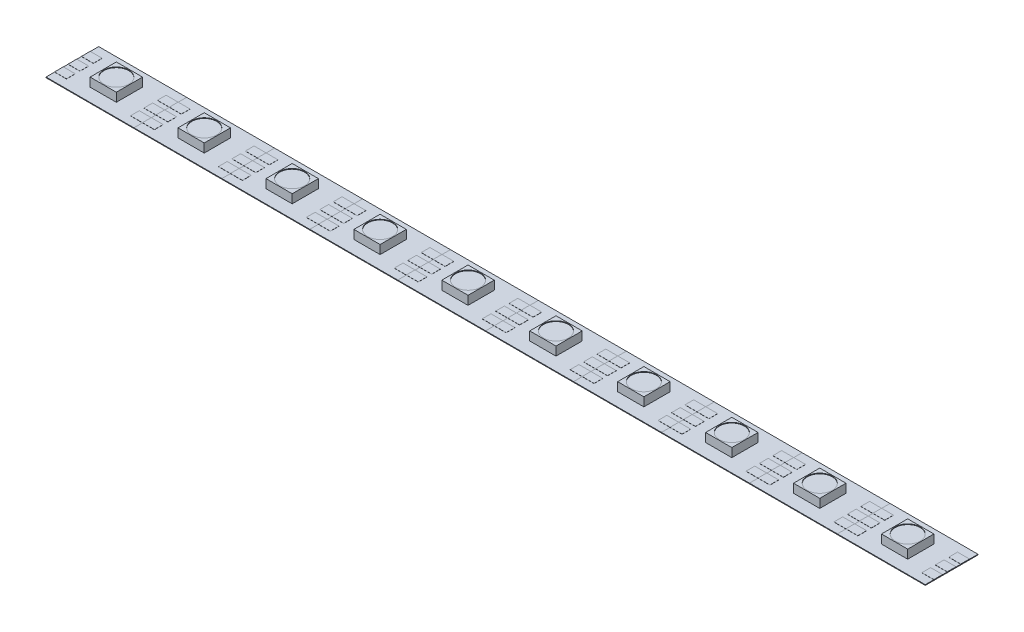
from build123d import *

# Parameters (mm, degrees)
SKETCH1_W           = 16.6116
SKETCH1_H           = 9.9568
BOSS_EXTRUDE1_DEPTH = 0.127
SKETCH3_W           = 4.953
SKETCH3_H           = 4.953
BOSS_EXTRUDE3_DEPTH = 1.651
SKETCH4_W           = 2.258810151
SKETCH4_H           = 1.651
BOSS_EXTRUDE4_DEPTH = 0.0254
SKETCH5_R           = 2.348345572
CUT_EXTRUDE1_DEPTH  = 0.127
LPATTERN1_COUNT     = 10
LPATTERN1_PITCH     = 16.6116


with BuildPart() as part:
    # Sketch1 → Boss-Extrude1 (new body)
    with BuildSketch(Plane(origin=(0, 0, 0), x_dir=(1, 0, 0), z_dir=(0, 1, 0))):
        Rectangle(SKETCH1_W, SKETCH1_H)
    extrude(amount=BOSS_EXTRUDE1_DEPTH)

    # Sketch3 → Boss-Extrude3 (add)
    with BuildSketch(Plane(origin=(0, 0.127, 0), x_dir=(1, 0, 0), z_dir=(0, 1, 0))):
        Rectangle(SKETCH3_W, SKETCH3_H)
    extrude(amount=BOSS_EXTRUDE3_DEPTH)

    # Sketch4 → Boss-Extrude4 (add)
    with BuildSketch(Plane(origin=(0, 0.127, 0), x_dir=(1, 0, 0), z_dir=(0, 1, 0))):
        with Locations((-7.176394925, 0)):
            Rectangle(SKETCH4_W, SKETCH4_H)
        with Locations((-7.176394925, 2.54)):
            Rectangle(SKETCH4_W, SKETCH4_H)
        with Locations((-7.176394925, -2.54)):
            Rectangle(SKETCH4_W, SKETCH4_H)
        with Locations((7.176394925, -2.54)):
            Rectangle(SKETCH4_W, SKETCH4_H)
        with Locations((7.176394925, 0)):
            Rectangle(SKETCH4_W, SKETCH4_H)
        with Locations((7.176394925, 2.54)):
            Rectangle(SKETCH4_W, SKETCH4_H)
    extrude(amount=BOSS_EXTRUDE4_DEPTH)

    # Sketch5 → Cut-Extrude1 (cut)
    with BuildSketch(Plane(origin=(0, 1.778, 0), x_dir=(1, 0, 0), z_dir=(0, 1, 0))):
        Circle(SKETCH5_R)
    extrude(amount=-CUT_EXTRUDE1_DEPTH, mode=Mode.SUBTRACT)


with BuildPart() as lpattern1_1:
    # LPattern1: pattern copy
    add(part.part.moved(Location(Vector(1, 0, 0) * (1 * LPATTERN1_PITCH))))


with BuildPart() as lpattern1_2:
    # LPattern1: pattern copy
    add(part.part.moved(Location(Vector(1, 0, 0) * (2 * LPATTERN1_PITCH))))


with BuildPart() as lpattern1_3:
    # LPattern1: pattern copy
    add(part.part.moved(Location(Vector(1, 0, 0) * (3 * LPATTERN1_PITCH))))


with BuildPart() as lpattern1_4:
    # LPattern1: pattern copy
    add(part.part.moved(Location(Vector(1, 0, 0) * (4 * LPATTERN1_PITCH))))


with BuildPart() as lpattern1_5:
    # LPattern1: pattern copy
    add(part.part.moved(Location(Vector(1, 0, 0) * (5 * LPATTERN1_PITCH))))


with BuildPart() as lpattern1_6:
    # LPattern1: pattern copy
    add(part.part.moved(Location(Vector(1, 0, 0) * (6 * LPATTERN1_PITCH))))


with BuildPart() as lpattern1_7:
    # LPattern1: pattern copy
    add(part.part.moved(Location(Vector(1, 0, 0) * (7 * LPATTERN1_PITCH))))


with BuildPart() as lpattern1_8:
    # LPattern1: pattern copy
    add(part.part.moved(Location(Vector(1, 0, 0) * (8 * LPATTERN1_PITCH))))


with BuildPart() as lpattern1_9:
    # LPattern1: pattern copy
    add(part.part.moved(Location(Vector(1, 0, 0) * (9 * LPATTERN1_PITCH))))


solid = Compound([part.part, lpattern1_1.part, lpattern1_2.part, lpattern1_3.part, lpattern1_4.part, lpattern1_5.part, lpattern1_6.part, lpattern1_7.part, lpattern1_8.part, lpattern1_9.part])
